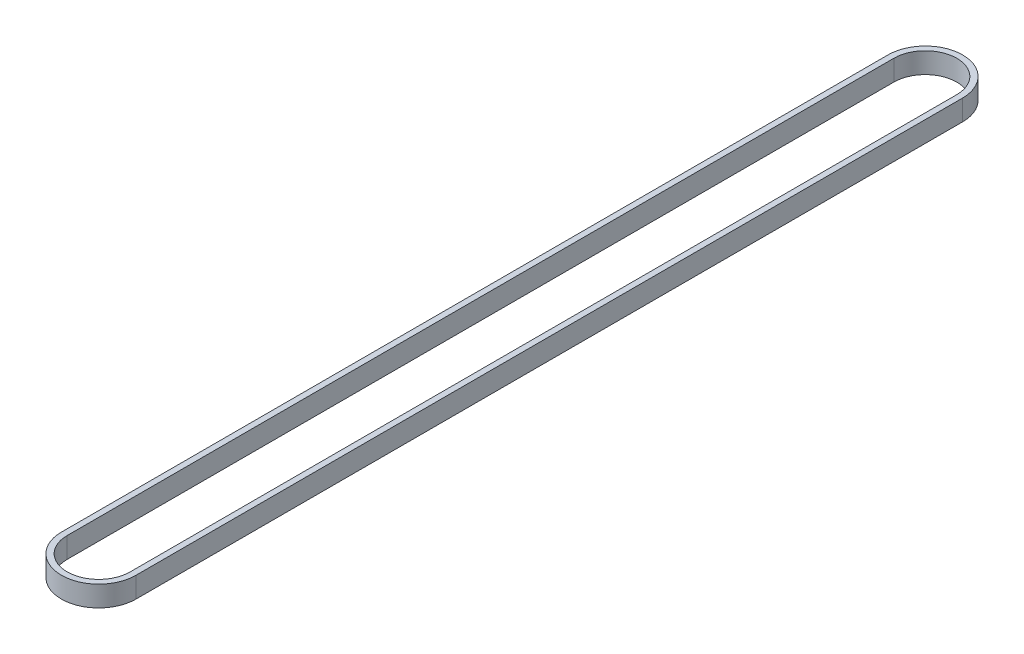
from build123d import *

# Parameters (mm, degrees)
BOSS_EXTRUDE1_DEPTH = 9


with BuildPart() as part:
    # Sketch1 → Boss-Extrude1 (new body)
    with BuildSketch(Plane(origin=(0, 0, 0), x_dir=(1, 0, 0), z_dir=(0, 1, 0))):
        with BuildLine():
            Line((-16.256, 360), (-16.256, 0))
            ThreePointArc((-16.256, 0), (0, -16.256), (16.256, 0))
            Line((16.256, 0), (16.256, 360))
            ThreePointArc((16.256, 360), (0, 376.256), (-16.256, 360))
        make_face()
        with BuildLine():
            Line((-13.716, 360), (-13.716, 0))
            ThreePointArc((-13.716, 0), (0, -13.716), (13.716, 0))
            Line((13.716, 0), (13.716, 360))
            ThreePointArc((13.716, 360), (0, 373.716), (-13.716, 360))
        make_face(mode=Mode.SUBTRACT)
    extrude(amount=BOSS_EXTRUDE1_DEPTH)


solid = part.part
